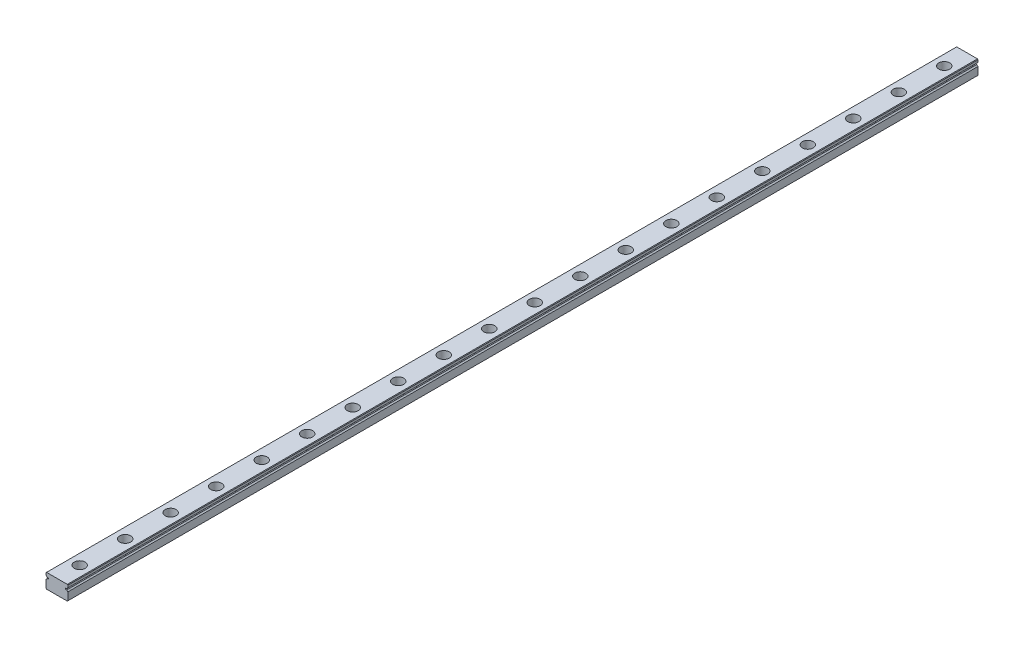
from build123d import *

# Parameters (mm, degrees)
EXTRUDE_1_DEPTH        = 500
SKETCH_2_R             = 3
SKETCH_2_R_2           = 1.75
CUT_EXTRUDE_1_DEPTH    = 4.5
SKETCH_2_2_R           = 1.75
CUT_EXTRUDE_2_DEPTH    = 9
PATTERN_LINEAR_1_COUNT = 20
PATTERN_LINEAR_1_PITCH = 25


with BuildPart() as part:
    # Sketch 1 → Extrude 1 (new body)
    with BuildSketch(Plane.XY):
        with BuildLine():
            Line((-6, 3.7), (-5.7, 4))
            Line((-5.7, 4), (5.7, 4))
            Line((5.7, 4), (6, 3.7))
            Line((6, 3.7), (6, 2.451013544))
            ThreePointArc((6, 2.451013544), (5.597935912, 2.202976267), (5.354599002, 1.798050138))
            Line((5.354599002, 1.798050138), (4.643514056, 1.798050138))
            Line((4.643514056, 1.798050138), (4.643514056, 1.201949862))
            Line((4.643514056, 1.201949862), (5.354599002, 1.201949862))
            ThreePointArc((5.354599002, 1.201949862), (5.597935912, 0.797023733), (6, 0.548986456))
            Line((6, 0.548986456), (6, -3.7))
            Line((6, -3.7), (5.7, -4))
            Line((5.7, -4), (-5.7, -4))
            Line((-5.7, -4), (-6, -3.7))
            Line((-6, -3.7), (-6, 0.548986456))
            ThreePointArc((-6, 0.548986456), (-5.597935912, 0.797023733), (-5.354599002, 1.201949862))
            Line((-5.354599002, 1.201949862), (-4.643514056, 1.201949862))
            Line((-4.643514056, 1.201949862), (-4.643514056, 1.798050138))
            Line((-4.643514056, 1.798050138), (-5.354599002, 1.798050138))
            ThreePointArc((-5.354599002, 1.798050138), (-5.597935912, 2.202976267), (-6, 2.451013544))
            Line((-6, 2.451013544), (-6, 3.7))
        make_face()
    extrude(amount=EXTRUDE_1_DEPTH)

    # Sketch 2 → Cut-Extrude 1 (cut)
    with BuildSketch(Plane(origin=(0, 4, 0), x_dir=(1, 0, 0), z_dir=(0, 1, 0))):
        with Locations((0, -12.5)):
            Circle(SKETCH_2_R)
        with Locations((0, -12.5)):
            Circle(SKETCH_2_R_2, mode=Mode.SUBTRACT)
    cut_extrude_1 = extrude(amount=-CUT_EXTRUDE_1_DEPTH, mode=Mode.SUBTRACT)

    # Sketch 2_2 → Cut-Extrude 2 (cut, through all)
    with BuildSketch(Plane(origin=(0, 4, 0), x_dir=(1, 0, 0), z_dir=(0, 1, 0))):
        with Locations((0, -12.5)):
            Circle(SKETCH_2_2_R)
    cut_extrude_2 = extrude(amount=-CUT_EXTRUDE_2_DEPTH, mode=Mode.SUBTRACT)

    # Pattern Linear 1: Cut-Extrude 1, Cut-Extrude 2 ×20
    with Locations(*[(0, 0, i * PATTERN_LINEAR_1_PITCH) for i in range(1, PATTERN_LINEAR_1_COUNT)]):
        add(cut_extrude_1, mode=Mode.SUBTRACT)
        add(cut_extrude_2, mode=Mode.SUBTRACT)


solid = part.part
